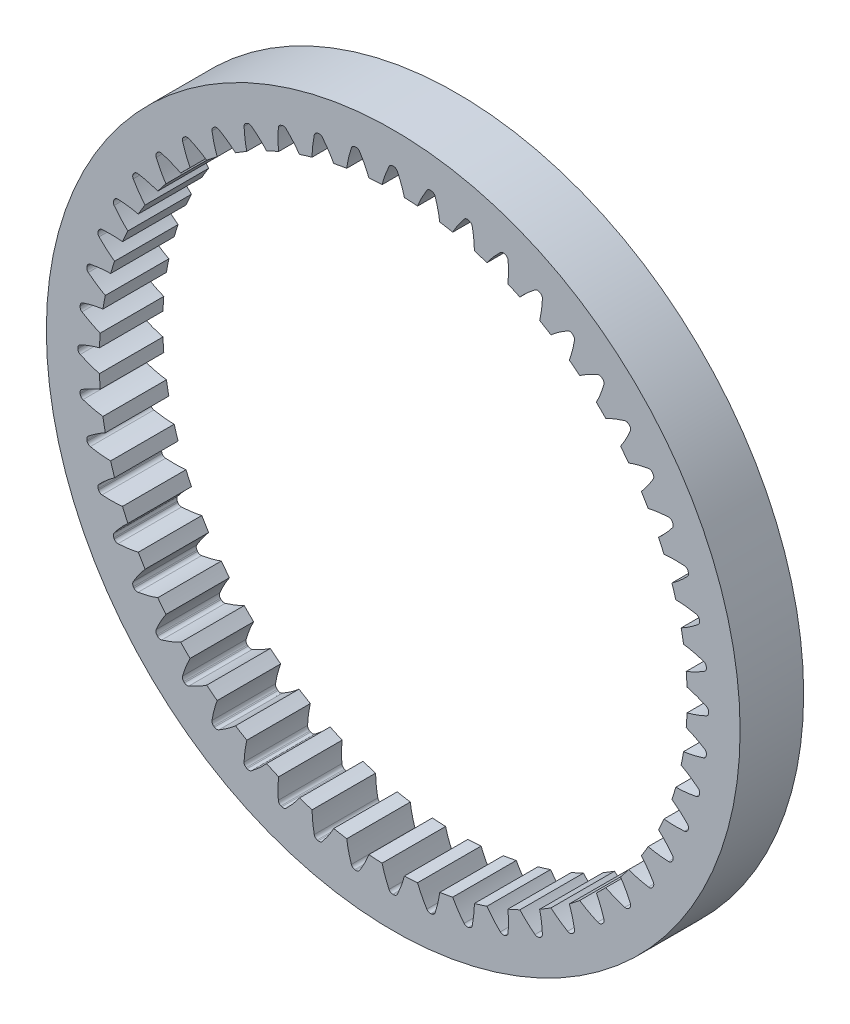
from build123d import *

# Parameters (mm, degrees)
SKETCH3_R           = 15.015
SKETCH3_R_2         = 12.725
BOSS_EXTRUDE2_DEPTH = 2.75
CUT_EXTRUDE2_DEPTH  = 3.75
CIRPATTERN1_COUNT   = 52


with BuildPart() as part:
    # Sketch3 → Boss-Extrude2 (new body)
    with BuildSketch(Plane.XY):
        Circle(SKETCH3_R)
        Circle(SKETCH3_R_2, mode=Mode.SUBTRACT)
    extrude(amount=BOSS_EXTRUDE2_DEPTH)

    # Sketch1 → Cut-Extrude2 (cut, through all)
    with BuildSketch(Plane.XY):
        with BuildLine():
            Line((12.715842886, 0.482664174), (12.715842886, -0.482664174))
            add(Edge.make_bspline(
                [(12.715842886, -0.482664174), (12.721803166, -0.481168563), (12.733538214, -0.478183782), (12.761000405, -0.471113835), (12.783660122, -0.464958545), (12.814566556, -0.45650787), (12.84043313, -0.449102916), (12.869251292, -0.44074033), (12.896184239, -0.432643593), (12.924178874, -0.424069151), (12.951413669, -0.415492271), (12.979054571, -0.406601136), (13.006291105, -0.397640788), (13.033780284, -0.388388809), (13.066078862, -0.37732125), (13.105675963, -0.363343904), (13.150866268, -0.347008462), (13.204331014, -0.326824677), (13.256501619, -0.30664778), (13.312504328, -0.283986598), (13.361750519, -0.26376529), (13.421399504, -0.238046577), (13.463262395, -0.219913533), (13.516263041, -0.195814358), (13.537643023, -0.186006691), (13.548793224, -0.180837387)],
                knots=[0.06236262, 0.06236262, 0.06236262, 0.06236262, 0.06236262, 0.090067024, 0.117771545, 0.145476147, 0.173180566, 0.200885104, 0.228589669, 0.256294118, 0.283998672, 0.311703205, 0.339407674, 0.367112233, 0.394816785, 0.422521219, 0.471487932, 0.526897007, 0.582305997, 0.63771503, 0.693124089, 0.748533108, 0.803942174, 0.859351157, 0.91476024, 0.91476024, 0.91476024, 0.91476024, 0.91476024], degree=4))
            ThreePointArc((13.548793224, -0.180837387), (13.622448151, -0.116514459), (13.649981154, -0.022682583))
            Line((13.649981154, -0.022682583), (13.649981154, 0.022682583))
            ThreePointArc((13.649981154, 0.022682583), (13.622448151, 0.116514459), (13.548793224, 0.180837387))
            add(Edge.make_bspline(
                [(12.715842886, 0.482664174), (12.721803166, 0.481168563), (12.733538214, 0.478183782), (12.761000405, 0.471113835), (12.783660122, 0.464958545), (12.814566556, 0.45650787), (12.84043313, 0.449102916), (12.869251292, 0.44074033), (12.896184239, 0.432643593), (12.924178874, 0.424069151), (12.951413669, 0.415492271), (12.979054571, 0.406601136), (13.006291105, 0.397640788), (13.033780284, 0.388388809), (13.066078862, 0.37732125), (13.105675963, 0.363343904), (13.150866268, 0.347008462), (13.204331014, 0.326824677), (13.256501619, 0.30664778), (13.312504328, 0.283986598), (13.361750519, 0.26376529), (13.421399504, 0.238046577), (13.463262395, 0.219913533), (13.516263041, 0.195814358), (13.537643023, 0.186006691), (13.548793224, 0.180837387)],
                knots=[0.06236262, 0.06236262, 0.06236262, 0.06236262, 0.06236262, 0.090067024, 0.117771545, 0.145476147, 0.173180566, 0.200885104, 0.228589669, 0.256294118, 0.283998672, 0.311703205, 0.339407674, 0.367112233, 0.394816785, 0.422521219, 0.471487932, 0.526897007, 0.582305997, 0.63771503, 0.693124089, 0.748533108, 0.803942174, 0.859351157, 0.91476024, 0.91476024, 0.91476024, 0.91476024, 0.91476024], degree=4))
        make_face()
    cut_extrude2 = extrude(amount=CUT_EXTRUDE2_DEPTH, mode=Mode.SUBTRACT)

    # CirPattern1: Cut-Extrude2 ×52 about axis
    cirpattern1_axis = Axis((0, 0, 2.8875), (0, 0, -1))
    for i in range(1, CIRPATTERN1_COUNT):
        add(cut_extrude2.rotate(cirpattern1_axis, i * 360 / CIRPATTERN1_COUNT), mode=Mode.SUBTRACT)


solid = part.part
